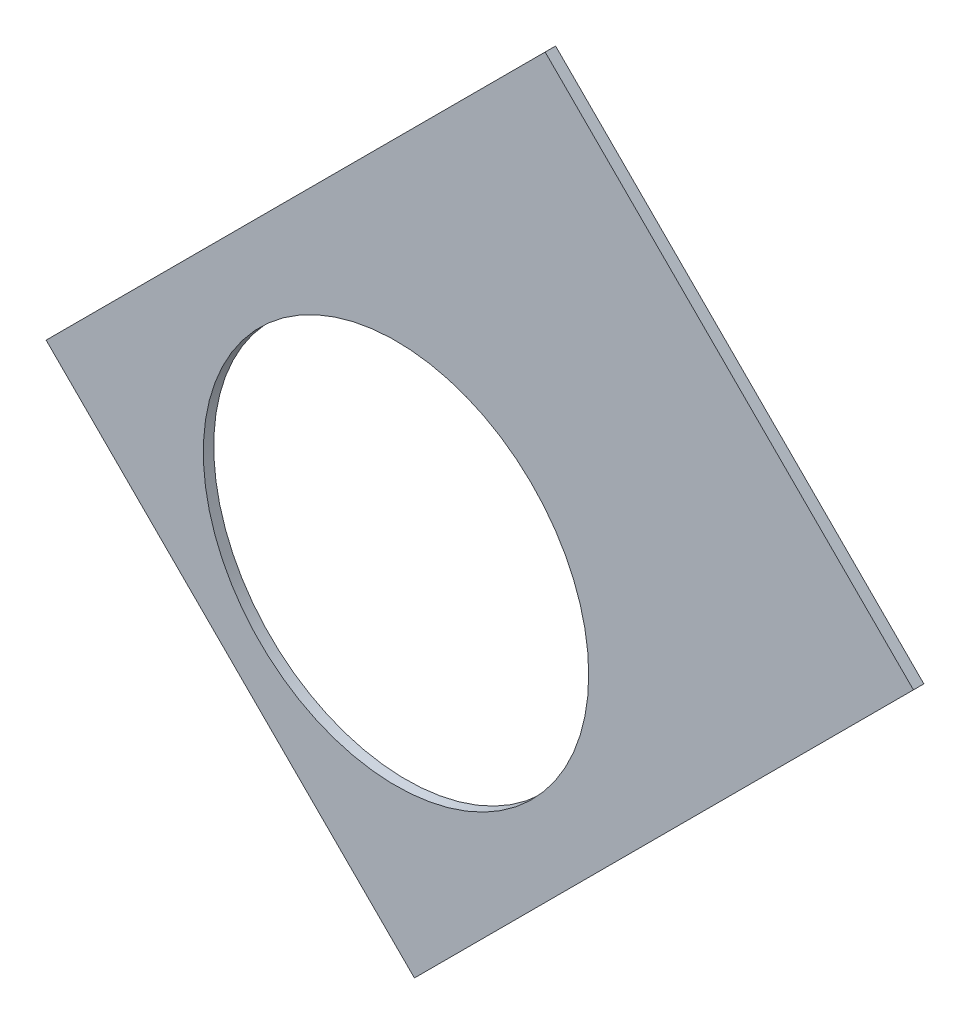
from build123d import *

# Parameters (mm, degrees)
BOSS_EXTRUDE1_DEPTH = 0.254
SKETCH2_R           = 4.699
CUT_EXTRUDE1_DEPTH  = 1.254
SKETCH3_W           = 2.54
SKETCH3_H           = 0.635
CUT_EXTRUDE2_DEPTH  = 1.254
SKETCH5_OUTSIDE_W   = 121.447
SKETCH5_OUTSIDE_H   = 109.618
CUT_EXTRUDE5_DEPTH  = 1.254


with BuildPart() as part:
    # Sketch1 → Boss-Extrude1 (new body)
    with BuildSketch(Plane.XY):
        with BuildLine():
            Line((67.21146711, 76.191723231), (8.696654013, 17.676910134))
            Line((8.696654013, 17.676910134), (7.228954972, 14.133571205))
            ThreePointArc((7.228954972, 14.133571205), (14.666587579, 6.075099489), (15.105587123, -4.88230096))
            Line((15.105587123, -4.88230096), (18.648926052, -6.35))
            Line((18.648926052, -6.35), (101.401368334, -6.35))
            ThreePointArc((101.401368334, -6.35), (93.866160503, 38.880636728), (67.21146711, 76.191723231))
        make_face()
        with BuildLine():
            Line((88.672924278, 6.35), (27.86051193, 6.35))
            ThreePointArc((27.86051193, 6.35), (26.399857642, 10.93517908), (24.190484974, 15.210228852))
            Line((24.190484974, 15.210228852), (67.191354125, 58.211098004))
            ThreePointArc((67.191354125, 58.211098004), (82.13289044, 34.020557137), (88.672924278, 6.35))
        make_face(mode=Mode.SUBTRACT)
    extrude(amount=BOSS_EXTRUDE1_DEPTH)

    # Sketch2 → Cut-Extrude1 (cut, through all)
    with BuildSketch(Plane.XY.offset(0.254)):
        with Locations((22.225, 0)):
            Circle(SKETCH2_R)
        with Locations((36.195, 0)):
            Circle(SKETCH2_R)
        with Locations((61.722, 0)):
            Circle(SKETCH2_R)
        with Locations((75.692, 0)):
            Circle(SKETCH2_R)
        with Locations((95.25, 0)):
            Circle(SKETCH2_R)
        with Locations((15.715448212, 15.715448212)):
            Circle(SKETCH2_R)
        with Locations((25.593729945, 25.593729945)):
            Circle(SKETCH2_R)
        with Locations((43.644044748, 43.644044748)):
            Circle(SKETCH2_R)
        with Locations((53.522326482, 53.522326482)):
            Circle(SKETCH2_R)
        with Locations((92.004434954, 24.652514046)):
            Circle(SKETCH2_R)
        with Locations((82.48891971, 47.625)):
            Circle(SKETCH2_R)
        with Locations((67.351920908, 67.351920908)):
            Circle(SKETCH2_R)
    extrude(amount=-CUT_EXTRUDE1_DEPTH, mode=Mode.SUBTRACT)

    # Sketch3 → Cut-Extrude2 (cut, through all)
    with BuildSketch(Plane.XY.offset(0.254)):
        Polygon((15.266435406, 24.246691527), (17.06248663, 26.042742751), (17.511499436, 25.593729945), (15.715448212, 23.797678721), align=None)
        Polygon((44.991083167, 53.971339288), (43.195031942, 52.175288063), (43.644044748, 51.726275257), (45.440095973, 53.522326482), align=None)
        with Locations((29.21, -6.0325)):
            Rectangle(SKETCH3_W, SKETCH3_H)
        with Locations((68.707, -6.0325)):
            Rectangle(SKETCH3_W, SKETCH3_H)
        Polygon((29.230733674, 38.210989795), (31.026784898, 40.007041019), (31.475797704, 39.558028213), (29.67974648, 37.761976989), align=None)
        Polygon((56.845021246, 65.825277367), (55.048970022, 64.029226143), (55.497982828, 63.580213337), (57.294034052, 65.376264561), align=None)
        with Locations((48.9585, -6.0325)):
            Rectangle(SKETCH3_W, SKETCH3_H)
        with Locations((85.471, -6.0325)):
            Rectangle(SKETCH3_W, SKETCH3_H)
        Polygon((99.935462164, 14.437711971), (100.266998693, 11.919442024), (101.526133667, 12.085210288), (101.194597138, 14.603480236), align=None)
        Polygon((93.765504959, 37.464305742), (94.938831965, 37.950313702), (93.966816047, 40.296967714), (92.793489041, 39.810959755), align=None)
        Polygon((79.327792988, 62.471156422), (80.874047017, 60.456038938), (81.88160576, 61.229165953), (80.33535173, 63.244283437), align=None)
        Polygon((13.593916116, 7.005422516), (14.565932035, 4.658768503), (15.739259041, 5.144776462), (14.767243123, 7.491430475), align=None)
    extrude(amount=-CUT_EXTRUDE2_DEPTH, mode=Mode.SUBTRACT)

    # Sketch5 outside → Cut-Extrude5 (cut, through all)
    with BuildSketch(Plane.XY.offset(0.254)):
        with Locations((54.4145, 34.921)):
            Rectangle(SKETCH5_OUTSIDE_W, SKETCH5_OUTSIDE_H)
        Polygon((14.368409794, 28.736819587), (26.536656838, 40.905066631), (40.905066631, 26.536656838), (28.736819587, 14.368409794), align=None, mode=Mode.SUBTRACT)
    extrude(amount=-CUT_EXTRUDE5_DEPTH, mode=Mode.SUBTRACT)


solid = part.part
